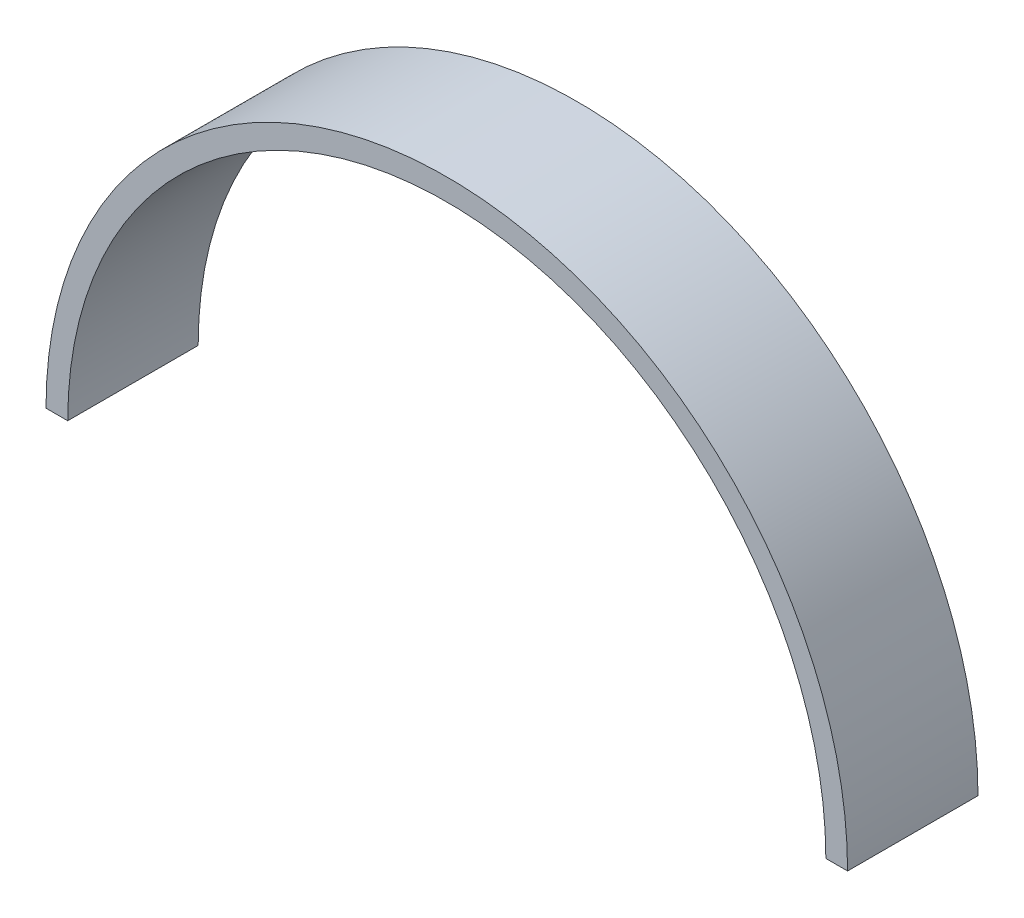
from build123d import *

# Parameters (mm, degrees)
BOSS_EXTRUDE1_DEPTH = 19.05


with BuildPart() as part:
    # Sketch1 → Boss-Extrude1 (new body)
    with BuildSketch(Plane.XY):
        with BuildLine():
            Line((-58.545, 0), (-55.37, 0))
            ThreePointArc((-55.37, 0), (0, 55.37), (55.37, 0))
            Line((55.37, 0), (58.545, 0))
            ThreePointArc((58.545, 0), (0, 58.545), (-58.545, 0))
        make_face()
    extrude(amount=BOSS_EXTRUDE1_DEPTH)


solid = part.part
